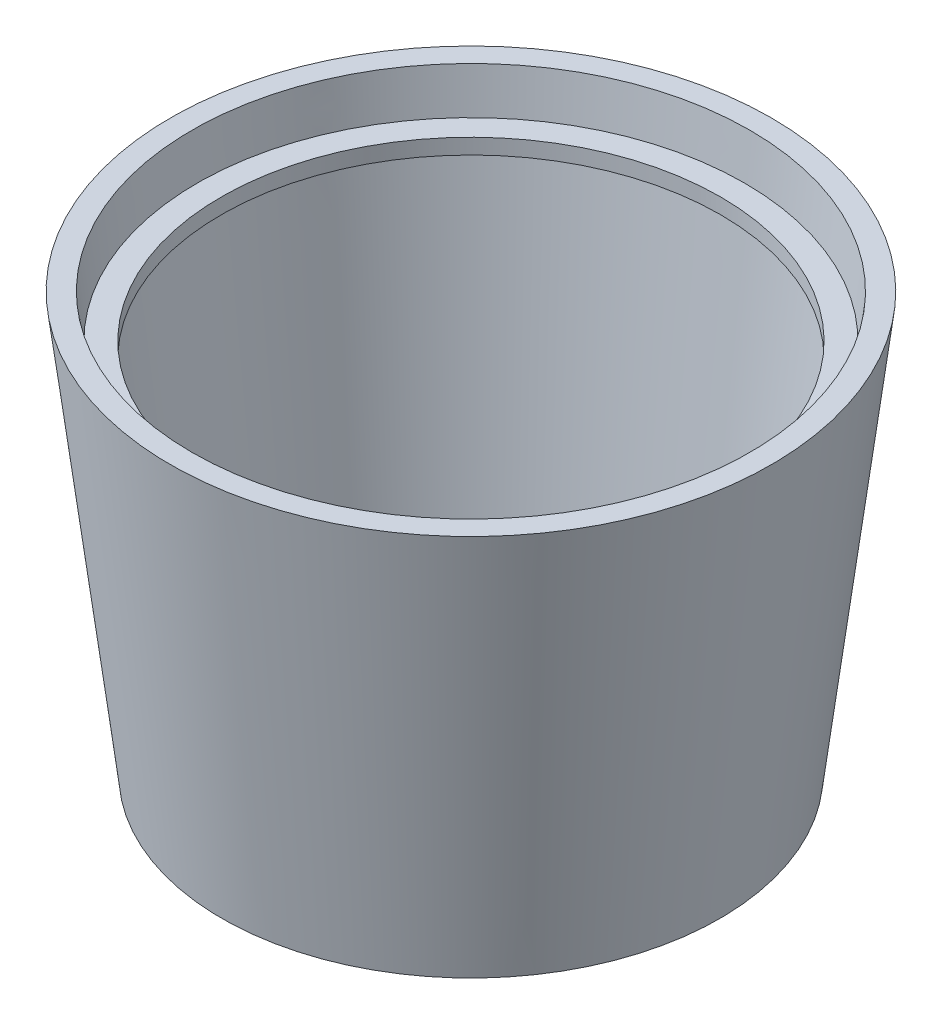
from build123d import *


with BuildPart() as part:
    # 草图1 → 旋转1 (revolve)
    with BuildSketch(Plane.XY):
        Polygon((-281.053886117, 0), (-210.969479767, 0), (-99.260265185, 909.798542754), (-145.756815863, 909.798542754), (-157.271259397, 816.020925686), (-209.399700553, 816.020925686), (-209.399700553, 782.547470572), (-152.785531171, 782.547470572), (-247.151294878, 14), (-281.053886117, 14), align=None)
    revolve(axis=Axis((-752, 0, 0), (0, 1, 0)))


solid = part.part
